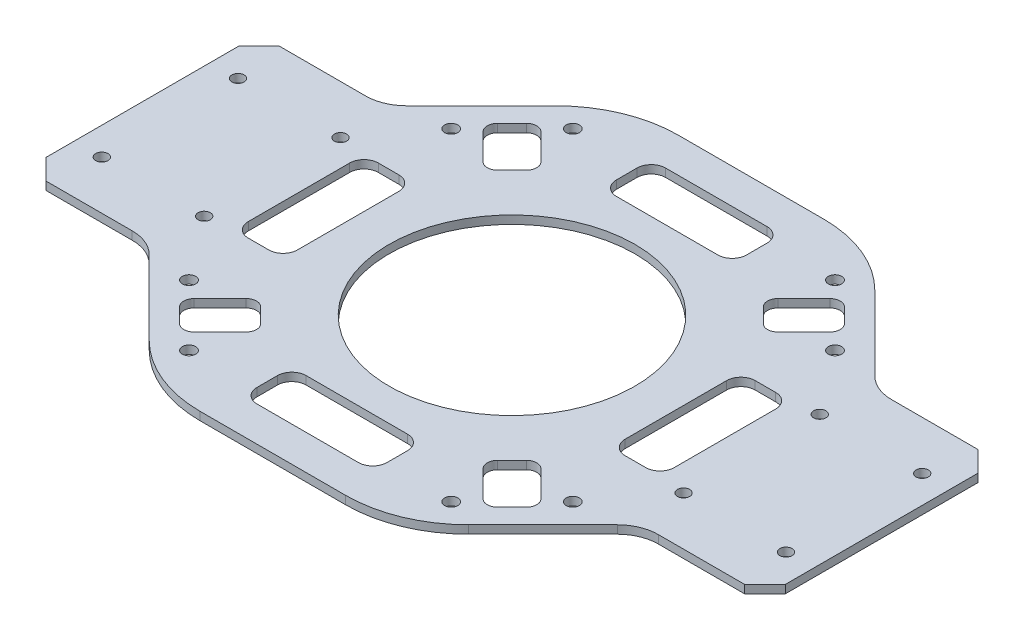
from build123d import *

# Parameters (mm, degrees)
SKETCH1_R           = 1.625
SKETCH1_R_2         = 1.5
SKETCH1_R_3         = 30
BOSS_EXTRUDE1_DEPTH = 2


with BuildPart() as part:
    # Sketch1 → Boss-Extrude1 (new body)
    with BuildSketch(Plane(origin=(0, 3.76, 0), x_dir=(1, 0, 0), z_dir=(0, 1, 0))):
        with BuildLine():
            Line((-17.763717472, -58.375), (17.763717472, -58.375))
            ThreePointArc((17.763717472, -58.375), (29.244220443, -56.091385975), (38.976920908, -49.588203436))
            Line((38.976920908, -49.588203436), (57.136192155, -31.428932188))
            ThreePointArc((57.136192155, -31.428932188), (60.380425644, -29.261204675), (64.207259967, -28.5))
            Line((64.207259967, -28.5), (85.25, -28.5))
            Line((85.25, -28.5), (90.25, -23.5))
            Line((90.25, -23.5), (90.25, 23.5))
            Line((90.25, 23.5), (85.25, 28.5))
            Line((85.25, 28.5), (64.207259967, 28.5))
            ThreePointArc((64.207259967, 28.5), (60.380425644, 29.261204675), (57.136192155, 31.428932188))
            Line((57.136192155, 31.428932188), (38.976920908, 49.588203436))
            ThreePointArc((38.976920908, 49.588203436), (29.244220443, 56.091385975), (17.763717472, 58.375))
            Line((17.763717472, 58.375), (-17.763717472, 58.375))
            ThreePointArc((-17.763717472, 58.375), (-29.244220443, 56.091385975), (-38.976920908, 49.588203436))
            Line((-38.976920908, 49.588203436), (-57.136192155, 31.428932188))
            ThreePointArc((-57.136192155, 31.428932188), (-60.380425644, 29.261204675), (-64.207259967, 28.5))
            Line((-64.207259967, 28.5), (-85.25, 28.5))
            Line((-85.25, 28.5), (-90.25, 23.5))
            Line((-90.25, 23.5), (-90.25, -23.5))
            Line((-90.25, -23.5), (-85.25, -28.5))
            Line((-85.25, -28.5), (-64.207259967, -28.5))
            ThreePointArc((-64.207259967, -28.5), (-60.380425644, -29.261204675), (-57.136192155, -31.428932188))
            Line((-57.136192155, -31.428932188), (-38.976920908, -49.588203436))
            ThreePointArc((-38.976920908, -49.588203436), (-29.244220443, -56.091385975), (-17.763717472, -58.375))
        make_face()
        with Locations((31.996581849, 46.845824254)):
            Circle(SKETCH1_R, mode=Mode.SUBTRACT)
        with Locations((31.996581849, -46.845824254)):
            Circle(SKETCH1_R, mode=Mode.SUBTRACT)
        with Locations((-31.996581849, 46.845824254)):
            Circle(SKETCH1_R, mode=Mode.SUBTRACT)
        with Locations((58.5, -16.625)):
            Circle(SKETCH1_R_2, mode=Mode.SUBTRACT)
        with Locations((-58.5, 16.625)):
            Circle(SKETCH1_R_2, mode=Mode.SUBTRACT)
        with Locations((-58.5, -16.625)):
            Circle(SKETCH1_R_2, mode=Mode.SUBTRACT)
        with Locations((58.5, 16.625)):
            Circle(SKETCH1_R_2, mode=Mode.SUBTRACT)
        with Locations((-83.5, 16.625)):
            Circle(SKETCH1_R_2, mode=Mode.SUBTRACT)
        with Locations((-83.5, -16.625)):
            Circle(SKETCH1_R_2, mode=Mode.SUBTRACT)
        with Locations((83.5, -16.625)):
            Circle(SKETCH1_R_2, mode=Mode.SUBTRACT)
        with Locations((83.5, 16.625)):
            Circle(SKETCH1_R_2, mode=Mode.SUBTRACT)
        Circle(SKETCH1_R_3, mode=Mode.SUBTRACT)
        with Locations((46.845824254, 31.996581849)):
            Circle(SKETCH1_R, mode=Mode.SUBTRACT)
        with Locations((46.845824254, -31.996581849)):
            Circle(SKETCH1_R, mode=Mode.SUBTRACT)
        with Locations((-46.845824254, 31.996581849)):
            Circle(SKETCH1_R, mode=Mode.SUBTRACT)
        with Locations((-46.845824254, -31.996581849)):
            Circle(SKETCH1_R, mode=Mode.SUBTRACT)
        with Locations((-31.996581849, -46.845824254)):
            Circle(SKETCH1_R, mode=Mode.SUBTRACT)
        with BuildLine():
            Line((-15.875, -46.375), (-15.875, -41.375))
            ThreePointArc((-15.875, -41.375), (-14.849873734, -38.900126266), (-12.375, -37.875))
            Line((-12.375, -37.875), (12.375, -37.875))
            ThreePointArc((12.375, -37.875), (14.849873734, -38.900126266), (15.875, -41.375))
            Line((15.875, -41.375), (15.875, -46.375))
            ThreePointArc((15.875, -46.375), (14.849873734, -48.849873734), (12.375, -49.875))
            Line((12.375, -49.875), (-12.375, -49.875))
            ThreePointArc((-12.375, -49.875), (-14.849873734, -48.849873734), (-15.875, -46.375))
        make_face(mode=Mode.SUBTRACT)
        with BuildLine():
            Line((15.875, 46.375), (15.875, 41.375))
            ThreePointArc((15.875, 41.375), (14.849873734, 38.900126266), (12.375, 37.875))
            Line((12.375, 37.875), (-12.375, 37.875))
            ThreePointArc((-12.375, 37.875), (-14.849873734, 38.900126266), (-15.875, 41.375))
            Line((-15.875, 41.375), (-15.875, 46.375))
            ThreePointArc((-15.875, 46.375), (-14.849873734, 48.849873734), (-12.375, 49.875))
            Line((-12.375, 49.875), (12.375, 49.875))
            ThreePointArc((12.375, 49.875), (14.849873734, 48.849873734), (15.875, 46.375))
        make_face(mode=Mode.SUBTRACT)
        with BuildLine():
            Line((-43.5, -15.875), (-48.5, -15.875))
            ThreePointArc((-48.5, -15.875), (-50.974873734, -14.849873734), (-52, -12.375))
            Line((-52, -12.375), (-52, 12.375))
            ThreePointArc((-52, 12.375), (-50.974873734, 14.849873734), (-48.5, 15.875))
            Line((-48.5, 15.875), (-43.5, 15.875))
            ThreePointArc((-43.5, 15.875), (-41.025126266, 14.849873734), (-40, 12.375))
            Line((-40, 12.375), (-40, -12.375))
            ThreePointArc((-40, -12.375), (-41.025126266, -14.849873734), (-43.5, -15.875))
        make_face(mode=Mode.SUBTRACT)
        with BuildLine():
            Line((-32.438523587, -28.902989681), (-28.902989681, -32.438523587))
            ThreePointArc((-28.902989681, -32.438523587), (-28.170756634, -34.20629054), (-28.902989681, -35.974057493))
            Line((-28.902989681, -35.974057493), (-35.266950712, -42.338018524))
            ThreePointArc((-35.266950712, -42.338018524), (-37.034717665, -43.070251571), (-38.802484618, -42.338018524))
            Line((-38.802484618, -42.338018524), (-42.338018524, -38.802484618))
            ThreePointArc((-42.338018524, -38.802484618), (-43.070251571, -37.034717665), (-42.338018524, -35.266950712))
            Line((-42.338018524, -35.266950712), (-35.974057493, -28.902989681))
            ThreePointArc((-35.974057493, -28.902989681), (-34.20629054, -28.170756634), (-32.438523587, -28.902989681))
        make_face(mode=Mode.SUBTRACT)
        with BuildLine():
            Line((32.438523587, 28.902989681), (28.902989681, 32.438523587))
            ThreePointArc((28.902989681, 32.438523587), (28.170756634, 34.20629054), (28.902989681, 35.974057493))
            Line((28.902989681, 35.974057493), (35.266950712, 42.338018524))
            ThreePointArc((35.266950712, 42.338018524), (37.034717665, 43.070251571), (38.802484618, 42.338018524))
            Line((38.802484618, 42.338018524), (42.338018524, 38.802484618))
            ThreePointArc((42.338018524, 38.802484618), (43.070251571, 37.034717665), (42.338018524, 35.266950712))
            Line((42.338018524, 35.266950712), (35.974057493, 28.902989681))
            ThreePointArc((35.974057493, 28.902989681), (34.20629054, 28.170756634), (32.438523587, 28.902989681))
        make_face(mode=Mode.SUBTRACT)
        with BuildLine():
            Line((28.902989681, -32.438523587), (32.438523587, -28.902989681))
            ThreePointArc((32.438523587, -28.902989681), (34.20629054, -28.170756634), (35.974057493, -28.902989681))
            Line((35.974057493, -28.902989681), (42.338018524, -35.266950712))
            ThreePointArc((42.338018524, -35.266950712), (43.070251571, -37.034717665), (42.338018524, -38.802484618))
            Line((42.338018524, -38.802484618), (38.802484618, -42.338018524))
            ThreePointArc((38.802484618, -42.338018524), (37.034717665, -43.070251571), (35.266950712, -42.338018524))
            Line((35.266950712, -42.338018524), (28.902989681, -35.974057493))
            ThreePointArc((28.902989681, -35.974057493), (28.170756634, -34.20629054), (28.902989681, -32.438523587))
        make_face(mode=Mode.SUBTRACT)
        with BuildLine():
            Line((-28.902989681, 32.438523587), (-32.438523587, 28.902989681))
            ThreePointArc((-32.438523587, 28.902989681), (-34.20629054, 28.170756634), (-35.974057493, 28.902989681))
            Line((-35.974057493, 28.902989681), (-42.338018524, 35.266950712))
            ThreePointArc((-42.338018524, 35.266950712), (-43.070251571, 37.034717665), (-42.338018524, 38.802484618))
            Line((-42.338018524, 38.802484618), (-38.802484618, 42.338018524))
            ThreePointArc((-38.802484618, 42.338018524), (-37.034717665, 43.070251571), (-35.266950712, 42.338018524))
            Line((-35.266950712, 42.338018524), (-28.902989681, 35.974057493))
            ThreePointArc((-28.902989681, 35.974057493), (-28.170756634, 34.20629054), (-28.902989681, 32.438523587))
        make_face(mode=Mode.SUBTRACT)
        with BuildLine():
            Line((43.5, 15.875), (48.5, 15.875))
            ThreePointArc((48.5, 15.875), (50.974873734, 14.849873734), (52, 12.375))
            Line((52, 12.375), (52, -12.375))
            ThreePointArc((52, -12.375), (50.974873734, -14.849873734), (48.5, -15.875))
            Line((48.5, -15.875), (43.5, -15.875))
            ThreePointArc((43.5, -15.875), (41.025126266, -14.849873734), (40, -12.375))
            Line((40, -12.375), (40, 12.375))
            ThreePointArc((40, 12.375), (41.025126266, 14.849873734), (43.5, 15.875))
        make_face(mode=Mode.SUBTRACT)
    extrude(amount=-BOSS_EXTRUDE1_DEPTH)


solid = part.part
